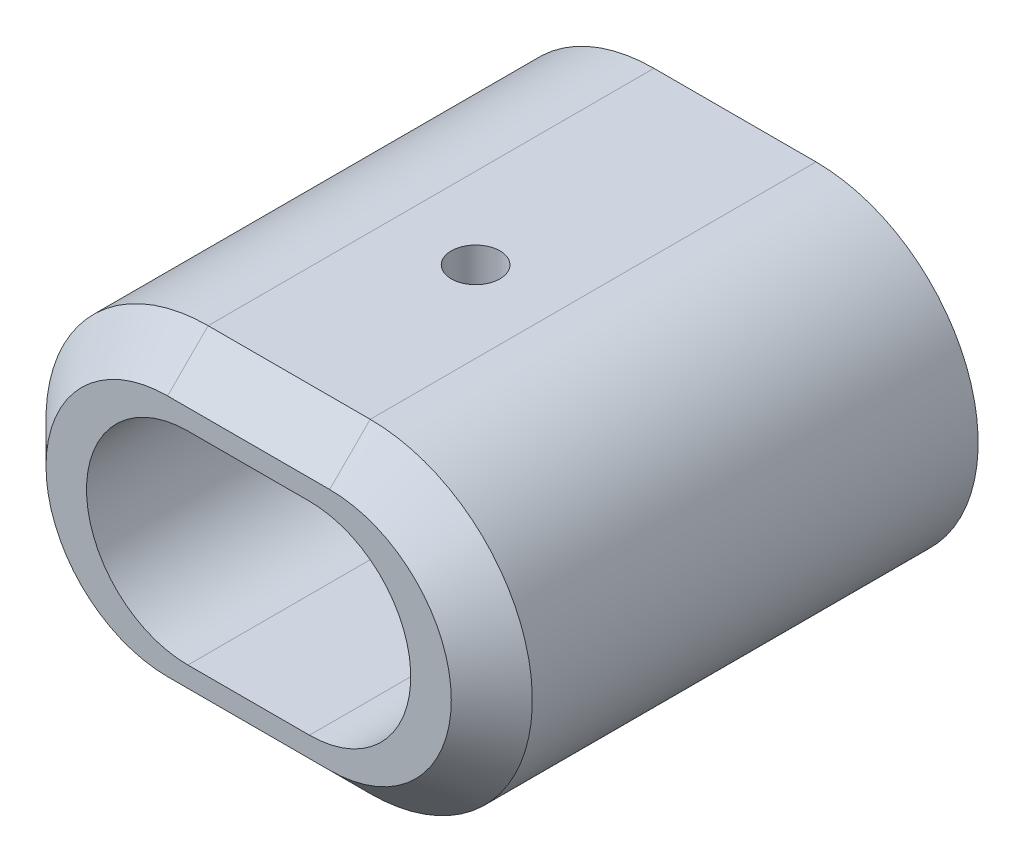
from build123d import *

# Parameters (mm, degrees)
BOSS_EXTRUDE1_DEPTH = 60
SKETCH4_R           = 3
CUT_EXTRUDE1_DEPTH  = 60
CHAMFER1_SIZE       = 5


with BuildPart() as part:
    # Sketch1 → Boss-Extrude1 (new body)
    with BuildSketch(Plane.XY):
        with BuildLine():
            Line((-10, 20), (10, 20))
            ThreePointArc((10, 20), (30, 0), (10, -20))
            Line((10, -20), (-10, -20))
            ThreePointArc((-10, -20), (-30, 0), (-10, 20))
        make_face()
        with BuildLine():
            Line((-7.5, 12.5), (7.5, 12.5))
            ThreePointArc((7.5, 12.5), (20, 0), (7.5, -12.5))
            Line((7.5, -12.5), (-7.5, -12.5))
            ThreePointArc((-7.5, -12.5), (-20, 0), (-7.5, 12.5))
        make_face(mode=Mode.SUBTRACT)
    extrude(amount=BOSS_EXTRUDE1_DEPTH)

    # Sketch4 → Cut-Extrude1 (cut)
    with BuildSketch(Plane.XZ.offset(20)):
        with Locations(Location((0, 32, 0), (0, 0, 270))):  # turned: the seam where the file's is
            Circle(SKETCH4_R)
    extrude(amount=-CUT_EXTRUDE1_DEPTH, mode=Mode.SUBTRACT)

    # Chamfer1
    chamfer1_edges = [part.edges().sort_by_distance(p)[0] for p in [
        (30, 0, 60),
        (0, 20, 60),
        (-30, 0, 60),
        (0, -20, 60),
    ]]
    chamfer(chamfer1_edges, length=CHAMFER1_SIZE)


solid = part.part
